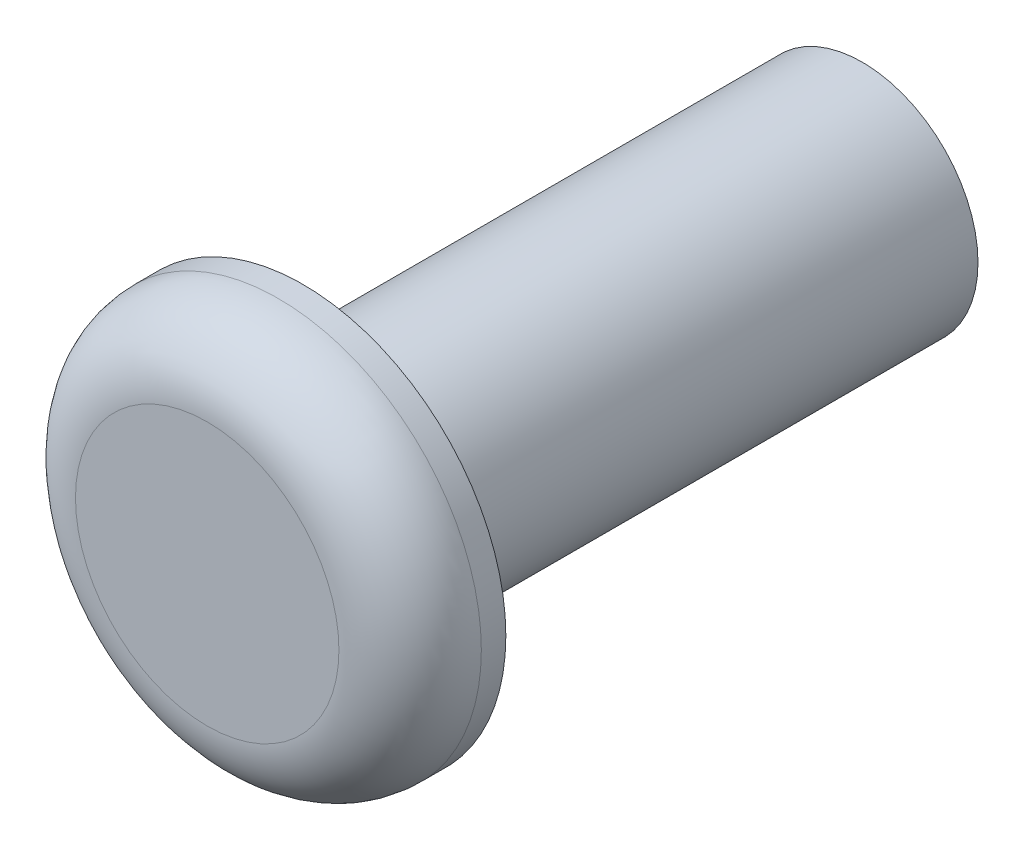
from build123d import *


with BuildPart() as part:
    # Sketch1 → Revolve1 (revolve)
    with BuildSketch(Plane(origin=(0, 0, 0), x_dir=(0, 0, -1), z_dir=(1, 0, 0))):
        with BuildLine():
            Line((0, 0), (0, 0.9398))
            ThreePointArc((0, 0.9398), (0.148789755, 1.299010245), (0.508, 1.4478))
            Line((0.508, 1.4478), (0.682863215, 1.4478))
            Line((0.682863215, 1.4478), (0.682863215, 0.8255))
            Line((0.682863215, 0.8255), (4.6736, 0.8255))
            Line((4.6736, 0.8255), (4.6736, 0))
            Line((4.6736, 0), (0, 0))
        make_face()
    revolve(axis=Axis((0, 0, 43.028816868), (0, 0, -1)))


solid = part.part
